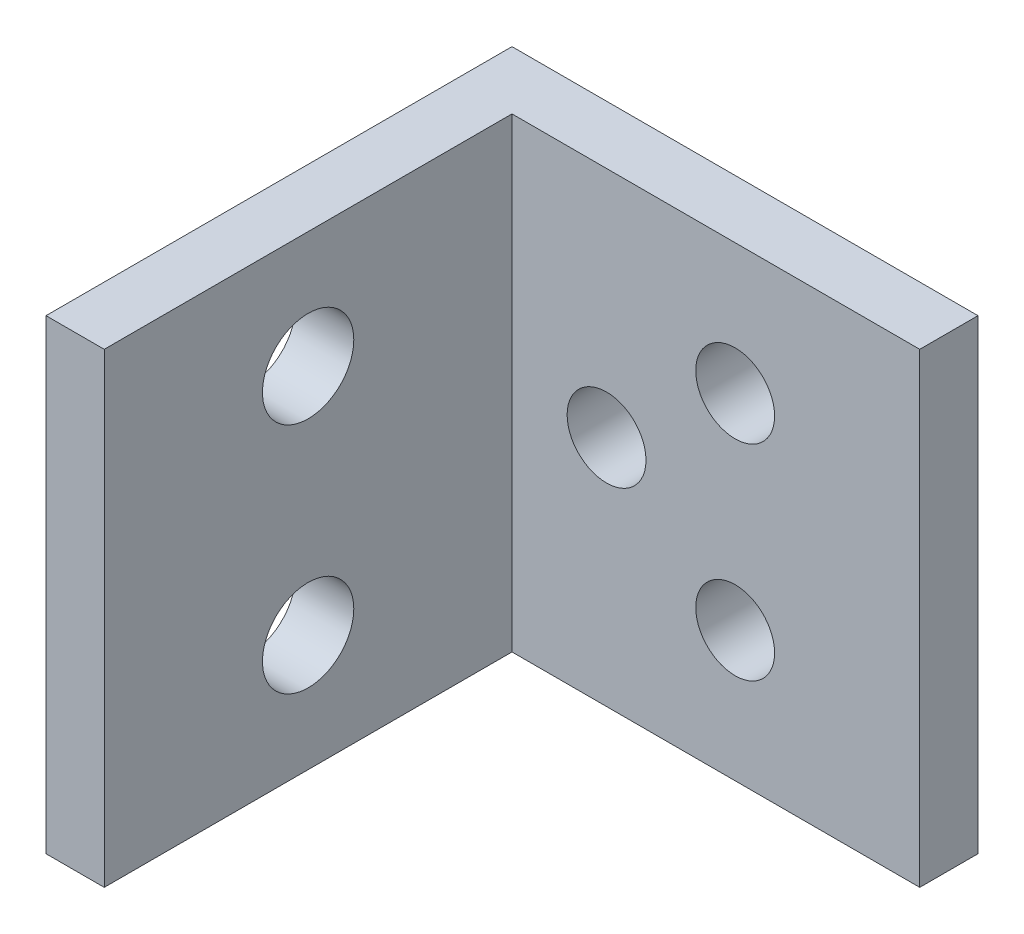
from build123d import *

# Parameters (mm, degrees)
EXTRUDE_THIN1_DEPTH = 25.4
SKETCH3_R           = 2.14884
CUT_EXTRUDE1_DEPTH  = 26.4
SKETCH4_R           = 2.4892
CUT_EXTRUDE2_DEPTH  = 4.175


with BuildPart() as part:
    # Sketch1 → Extrude-Thin1 (new body)
    with BuildSketch(Plane(origin=(0, 0, 0), x_dir=(1, 0, 0), z_dir=(0, 1, 0))):
        Polygon((0, -25.4), (0, 0), (25.4, 0), (25.4, -3.175), (3.175, -3.175), (3.175, -25.4), align=None)
    extrude(amount=EXTRUDE_THIN1_DEPTH)

    # Sketch3 → Cut-Extrude1 (cut, through all)
    with BuildSketch(Plane(origin=(0, 0, 0), x_dir=(-1, 0, 0), z_dir=(0, 0, -1))):
        with Locations((-8.32866, 12.7)):
            Circle(SKETCH3_R)
        with Locations((-15.33906, 7.10946)):
            Circle(SKETCH3_R)
        with Locations((-15.33906, 18.29054)):
            Circle(SKETCH3_R)
    extrude(amount=-CUT_EXTRUDE1_DEPTH, mode=Mode.SUBTRACT)

    # Sketch4 → Cut-Extrude2 (cut, through all)
    with BuildSketch(Plane(origin=(3.175, 0, 0), x_dir=(0, 0, -1), z_dir=(1, 0, 0))):
        with Locations((-14.2875, 6.35)):
            Circle(SKETCH4_R)
        with Locations((-14.2875, 19.05)):
            Circle(SKETCH4_R)
    extrude(amount=-CUT_EXTRUDE2_DEPTH, mode=Mode.SUBTRACT)


solid = part.part
